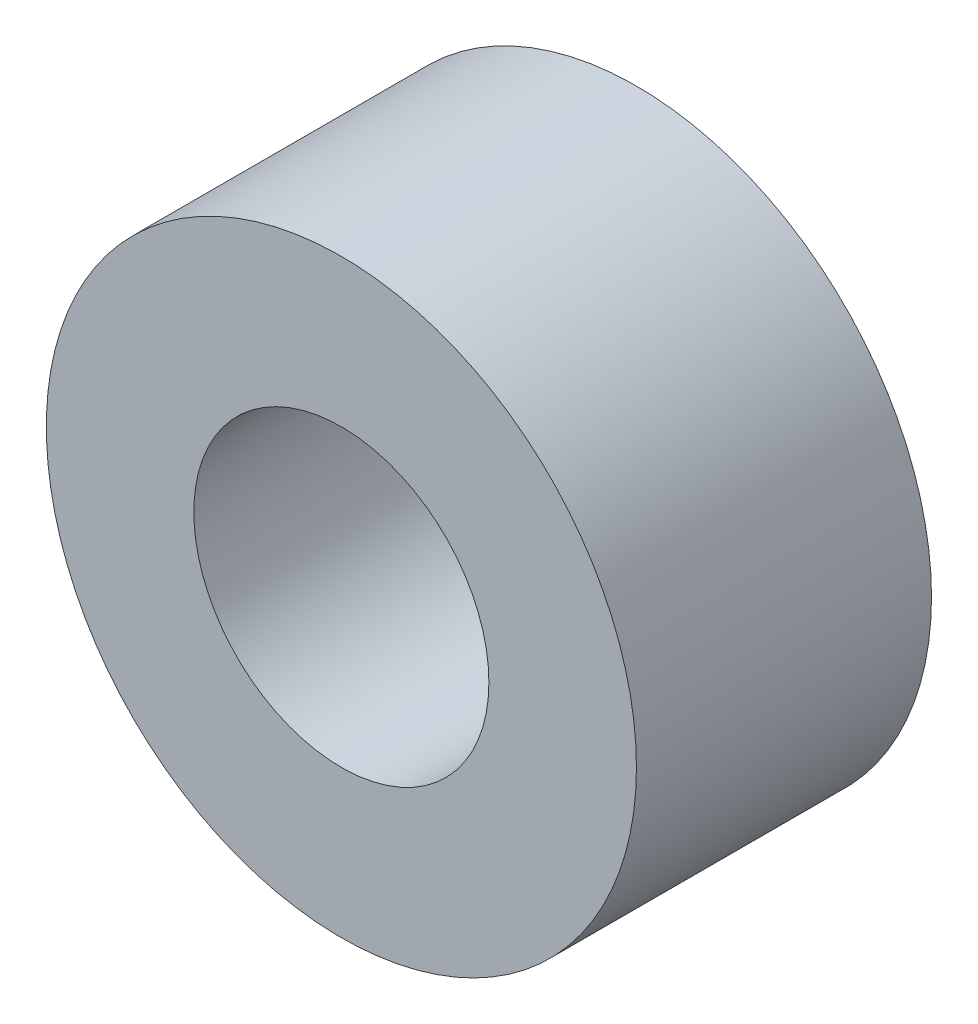
from build123d import *

# Parameters (mm, degrees)
SKETCH1_R           = 6.35
SKETCH1_R_2         = 3.175
BOSS_EXTRUDE1_DEPTH = 6.35


with BuildPart() as part:
    # Sketch1 → Boss-Extrude1 (new body)
    with BuildSketch(Plane.XY):
        Circle(SKETCH1_R)
        Circle(SKETCH1_R_2, mode=Mode.SUBTRACT)
    extrude(amount=BOSS_EXTRUDE1_DEPTH)


solid = part.part
